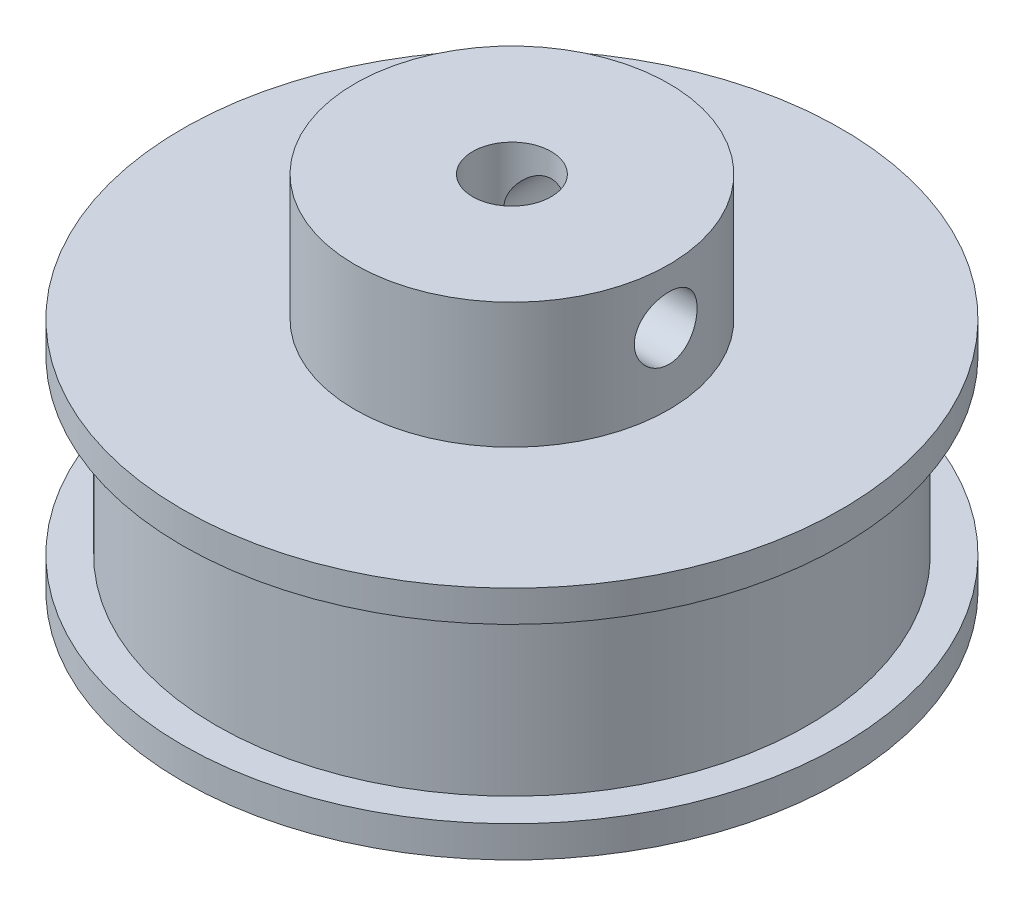
from build123d import *

# Parameters (mm, degrees)
SKETCH1_R           = 21
BOSS_EXTRUDE1_DEPTH = 2
SKETCH2_R           = 18.85
BOSS_EXTRUDE2_DEPTH = 11
SKETCH3_R           = 21
BOSS_EXTRUDE3_DEPTH = 2
SKETCH4_R           = 10
BOSS_EXTRUDE4_DEPTH = 8
SKETCH5_R           = 2.5
CUT_EXTRUDE1_DEPTH  = 24
SKETCH6_R           = 2
CUT_EXTRUDE2_DEPTH  = 22
CIRPATTERN1_COUNT   = 2
CIRPATTERN1_ANGLE   = 90


with BuildPart() as part:
    # Sketch1 → Boss-Extrude1 (new body)
    with BuildSketch(Plane(origin=(0, 0, 0), x_dir=(1, 0, 0), z_dir=(0, 1, 0))):
        Circle(SKETCH1_R)
    extrude(amount=BOSS_EXTRUDE1_DEPTH)

    # Sketch2 → Boss-Extrude2 (add)
    with BuildSketch(Plane(origin=(0, 2, 0), x_dir=(1, 0, 0), z_dir=(0, 1, 0))):
        Circle(SKETCH2_R)
    extrude(amount=BOSS_EXTRUDE2_DEPTH)

    # Sketch3 → Boss-Extrude3 (add)
    with BuildSketch(Plane(origin=(0, 13, 0), x_dir=(1, 0, 0), z_dir=(0, 1, 0))):
        Circle(SKETCH3_R)
    extrude(amount=BOSS_EXTRUDE3_DEPTH)

    # Sketch4 → Boss-Extrude4 (add)
    with BuildSketch(Plane(origin=(0, 15, 0), x_dir=(1, 0, 0), z_dir=(0, 1, 0))):
        Circle(SKETCH4_R)
    extrude(amount=BOSS_EXTRUDE4_DEPTH)

    # Sketch5 → Cut-Extrude1 (cut, through all)
    with BuildSketch(Plane(origin=(0, 23, 0), x_dir=(1, 0, 0), z_dir=(0, 1, 0))):
        Circle(SKETCH5_R)
    extrude(amount=-CUT_EXTRUDE1_DEPTH, mode=Mode.SUBTRACT)

    # Sketch6 → Cut-Extrude2 (cut, through all)
    with BuildSketch(Plane.XY):
        with Locations((0, 19.5)):
            Circle(SKETCH6_R)
    cut_extrude2 = extrude(amount=-CUT_EXTRUDE2_DEPTH, mode=Mode.SUBTRACT)

    # CirPattern1: Cut-Extrude2 ×2 about axis
    cirpattern1_axis = Axis((0, 23, 0), (0, -1, 0))
    for i in range(1, CIRPATTERN1_COUNT):
        add(cut_extrude2.rotate(cirpattern1_axis, i * CIRPATTERN1_ANGLE / (CIRPATTERN1_COUNT - 1)), mode=Mode.SUBTRACT)


solid = part.part
